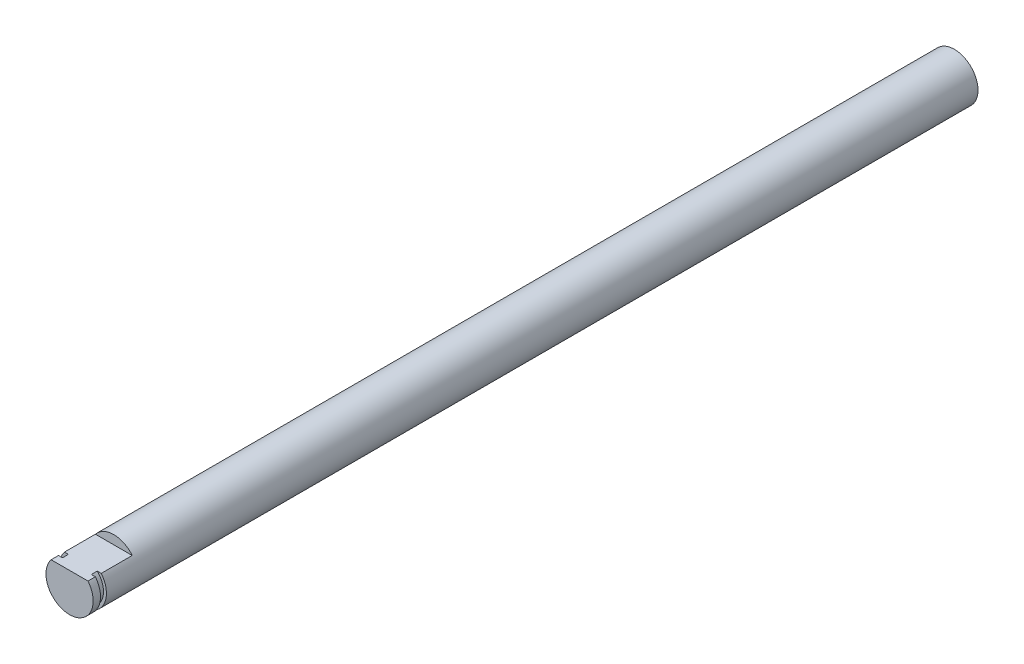
from build123d import *

# Parameters (mm, degrees)
SKETCH1_R           = 4
BOSS_EXTRUDE1_DEPTH = 150
CUT_EXTRUDE1_DEPTH  = 7.5
SKETCH3_R           = 4
SKETCH3_R_2         = 3.5
CUT_EXTRUDE2_DEPTH  = 1


with BuildPart() as part:
    # Sketch1 → Boss-Extrude1 (new body)
    with BuildSketch(Plane.XY):
        Circle(SKETCH1_R)
    extrude(amount=BOSS_EXTRUDE1_DEPTH)

    # Sketch2 → Cut-Extrude1 (cut)
    with BuildSketch(Plane.XY.offset(150)):
        with BuildLine():
            Line((3.122498999, 2.5), (-3.122498999, 2.5))
            ThreePointArc((-3.122498999, 2.5), (0, 4), (3.122498999, 2.5))
        make_face()
    extrude(amount=-CUT_EXTRUDE1_DEPTH, mode=Mode.SUBTRACT)

    # Sketch3 → Cut-Extrude2 (cut)
    with BuildSketch(Plane.XY.offset(148.75)):
        Circle(SKETCH3_R)
        Circle(SKETCH3_R_2, mode=Mode.SUBTRACT)
    extrude(amount=-CUT_EXTRUDE2_DEPTH, mode=Mode.SUBTRACT)


solid = part.part
